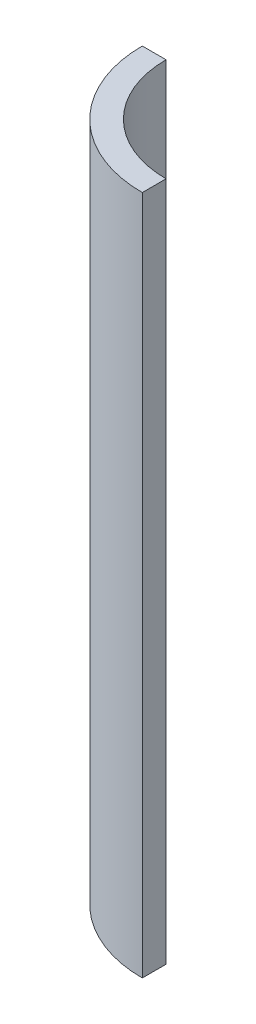
from build123d import *

# Parameters (mm, degrees)
BOSS_EXTRUDE1_DEPTH = 544.576


with BuildPart() as part:
    # Sketch1 → Boss-Extrude1 (new body)
    with BuildSketch(Plane(origin=(0, 0, 0), x_dir=(1, 0, 0), z_dir=(0, 1, 0))):
        with BuildLine():
            Line((0, -82.55), (0, -101.6))
            ThreePointArc((0, -101.6), (-71.842048969, -71.842048969), (-101.6, 0))
            Line((-101.6, 0), (-82.55, 0))
            ThreePointArc((-82.55, 0), (-58.371664787, -58.371664787), (0, -82.55))
        make_face()
    extrude(amount=BOSS_EXTRUDE1_DEPTH)


solid = part.part
